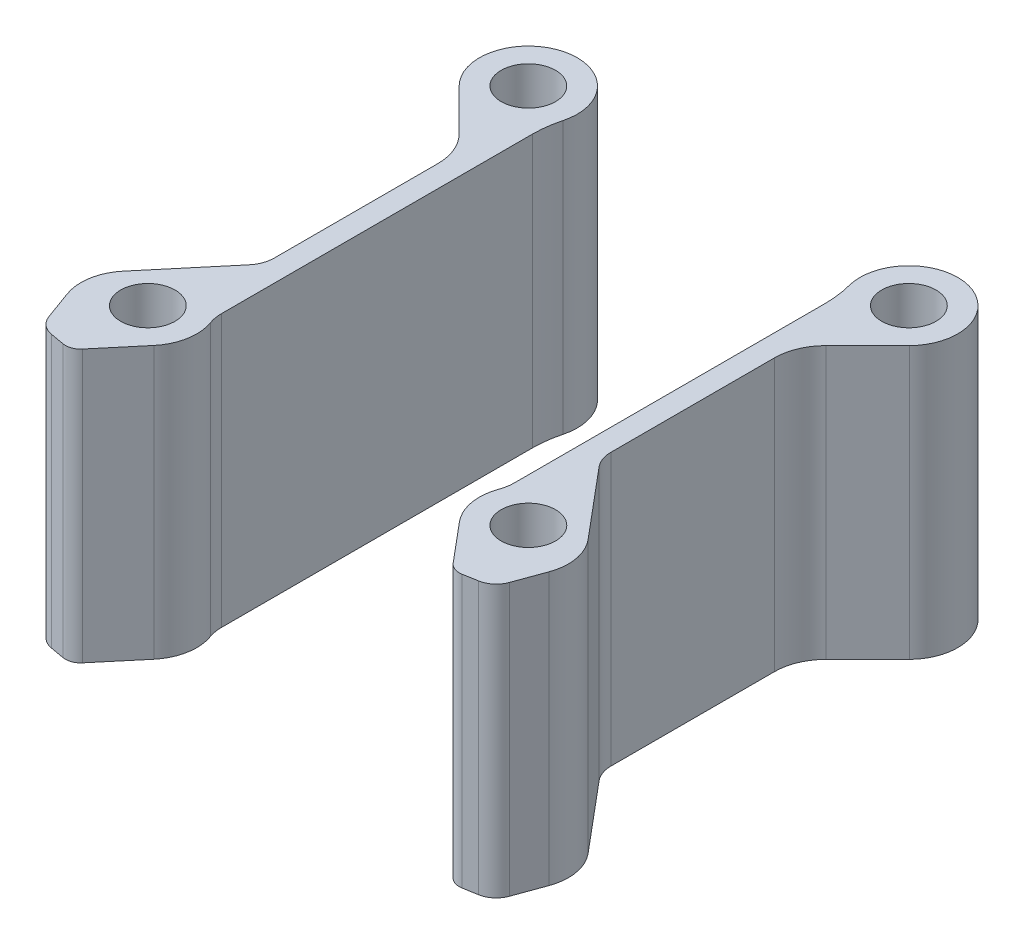
from build123d import *

# Parameters (mm, degrees)
SKETCH1_R             = 2.5
BOSS_EXTRUDE1_DEPTH   = 25
BOSS_EXTRUDE1_2_DEPTH = 25


with BuildPart() as part:
    # Sketch1 → Boss-Extrude1 (new body)
    with BuildSketch(Plane(origin=(0, 0, 0), x_dir=(1, 0, 0), z_dir=(0, 1, 0))):
        with BuildLine():
            Line((-3.341296497, -19.112401329), (-0.3389066, -22.6905175))
            ThreePointArc((-0.3389066, -22.6905175), (0.246348597, -23.100317695), (0.958094672, -23.162586214))
            Line((0.958094672, -23.162586214), (2.249788922, -22.934822271))
            ThreePointArc((2.249788922, -22.934822271), (3.188072996, -22.497290733), (3.781885701, -21.649235711))
            Line((3.781885701, -21.649235711), (4.758780701, -18.965229871))
            ThreePointArc((4.758780701, -18.965229871), (4.958196561, -16.68492284), (3.9905929, -14.610480748))
            Line((3.9905929, -14.610480748), (-1.296389221, -8.311556522))
            ThreePointArc((-1.296389221, -8.311556522), (-1.75637948, -7.515030148), (-1.916135173, -6.609202669))
            Line((-1.916135173, -6.609202669), (-1.916135173, 8.432064567))
            ThreePointArc((-1.916135173, 8.432064567), (-1.55553903, 10.244903795), (-0.528648097, 11.781754684))
            Line((-0.528648097, 11.781754684), (3.308214372, 15.618617153))
            ThreePointArc((3.308214372, 15.618617153), (1.260788565, 23.129420707), (-4.242964246, 17.623712083))
            ThreePointArc((-4.242964246, 17.623712083), (-3.998188362, 16.383912683), (-3.916135173, 15.122847633))
            Line((-3.916135173, 15.122847633), (-3.916135173, -13.477152367))
            ThreePointArc((-3.916135173, -13.477152367), (-3.969707578, -14.096623199), (-4.12883403, -14.697699638))
            ThreePointArc((-4.12883403, -14.697699638), (-4.32415693, -17.010138399), (-3.341296497, -19.112401329))
        make_face()
        with Locations((0.105906372, 18.780139488)):
            Circle(SKETCH1_R, mode=Mode.SUBTRACT)
        with Locations((0.105906372, -16.219860512)):
            Circle(SKETCH1_R, mode=Mode.SUBTRACT)
    extrude(amount=BOSS_EXTRUDE1_DEPTH)


with BuildPart() as body_2:
    # Sketch1 → Boss-Extrude1 2 (new body)
    with BuildSketch(Plane(origin=(0, 0, 0), x_dir=(1, 0, 0), z_dir=(0, 1, 0))):
        with BuildLine():
            Line((-30.872052083, 15.122847633), (-30.872052083, -13.477152367))
            ThreePointArc((-30.872052083, -13.477152367), (-30.818479677, -14.096623199), (-30.659353226, -14.697699638))
            ThreePointArc((-30.659353226, -14.697699638), (-30.464030325, -17.010138399), (-31.446890758, -19.112401329))
            Line((-31.446890758, -19.112401329), (-34.449280656, -22.6905175))
            ThreePointArc((-34.449280656, -22.6905175), (-35.034535852, -23.100317695), (-35.746281927, -23.162586214))
            Line((-35.746281927, -23.162586214), (-37.037976177, -22.934822271))
            ThreePointArc((-37.037976177, -22.934822271), (-37.976260251, -22.497290733), (-38.570072956, -21.649235711))
            Line((-38.570072956, -21.649235711), (-39.546967957, -18.965229871))
            ThreePointArc((-39.546967957, -18.965229871), (-39.746383816, -16.68492284), (-38.778780155, -14.610480748))
            Line((-38.778780155, -14.610480748), (-33.491798034, -8.311556522))
            ThreePointArc((-33.491798034, -8.311556522), (-33.031807776, -7.515030148), (-32.872052083, -6.609202669))
            Line((-32.872052083, -6.609202669), (-32.872052083, 8.432064567))
            ThreePointArc((-32.872052083, 8.432064567), (-33.232648225, 10.244903795), (-34.259539159, 11.781754684))
            Line((-34.259539159, 11.781754684), (-38.096401628, 15.618617153))
            ThreePointArc((-38.096401628, 15.618617153), (-36.04897582, 23.129420707), (-30.545223009, 17.623712083))
            ThreePointArc((-30.545223009, 17.623712083), (-30.789998893, 16.383912683), (-30.872052083, 15.122847633))
        make_face()
        with Locations((-34.894093628, -16.219860512)):
            Circle(SKETCH1_R, mode=Mode.SUBTRACT)
        with Locations((-34.894093628, 18.780139488)):
            Circle(SKETCH1_R, mode=Mode.SUBTRACT)
    extrude(amount=BOSS_EXTRUDE1_2_DEPTH)


solid = Compound([part.part, body_2.part])
